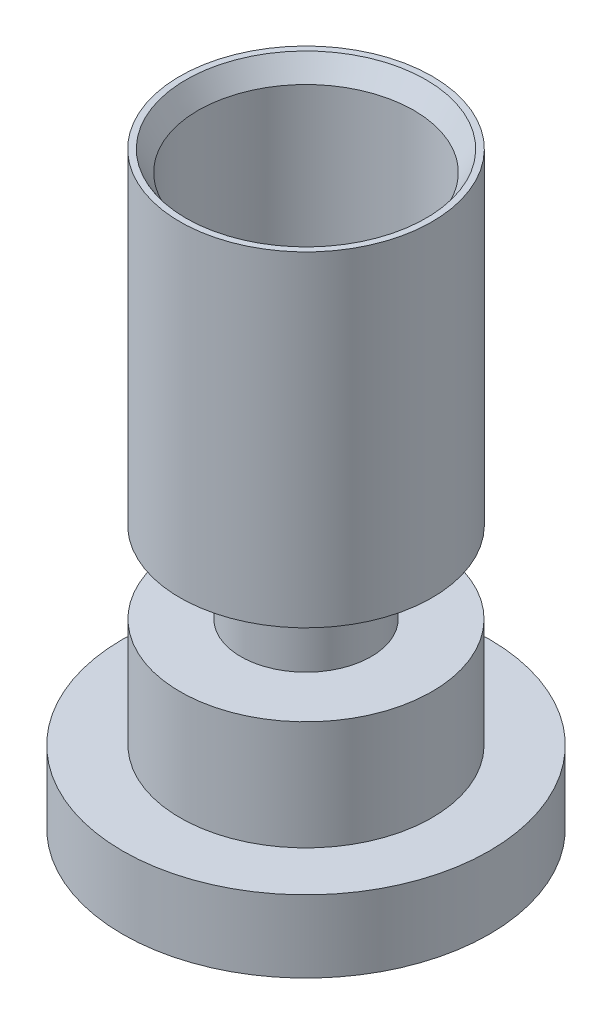
from build123d import *

# Parameters (mm, degrees)
CHAMFER1_SIZE  = 0.5
CHAMFER1_SIZE2 = 0.3
CHAMFER2_SIZE  = 0.5
CHAMFER2_SIZE2 = 0.75


with BuildPart() as part:
    # Sketch1 → Revolve1 (revolve)
    with BuildSketch(Plane.XY):
        Polygon((3.75, 0), (3.75, 1.16), (1.6, 1.16), (1.6, 3.45), (0.625, 3.45), (0.625, 6.44), (2.645, 6.44), (2.645, 14.44), (3.095, 14.44), (3.095, 5.95), (1.6, 5.95), (1.6, 4.45), (3.09, 4.45), (3.09, 1.77), (4.5, 1.77), (4.5, 0), align=None)
    revolve(axis=Axis((0, 0, 0), (0, 1, 0)))

    # Chamfer1
    chamfer1_edges = [part.edges().sort_by_distance(p)[0] for p in [
        (-2.645, 14.44, 0),
    ]]
    chamfer1_side = [part.faces().sort_by_distance(p)[0] for p in [
        (-2.645, 10.44, 0),
    ]]
    chamfer(chamfer1_edges, length=CHAMFER1_SIZE, length2=CHAMFER1_SIZE2, reference=chamfer1_side[0])

    # Chamfer2
    chamfer2_edges = [part.edges().sort_by_distance(p)[0] for p in [
        (-3.095, 5.95, 0),
    ]]
    chamfer2_side = [part.faces().sort_by_distance(p)[0] for p in [
        (-3.095, 10.195, 0),
    ]]
    chamfer(chamfer2_edges, length=CHAMFER2_SIZE, length2=CHAMFER2_SIZE2, reference=chamfer2_side[0])


solid = part.part
